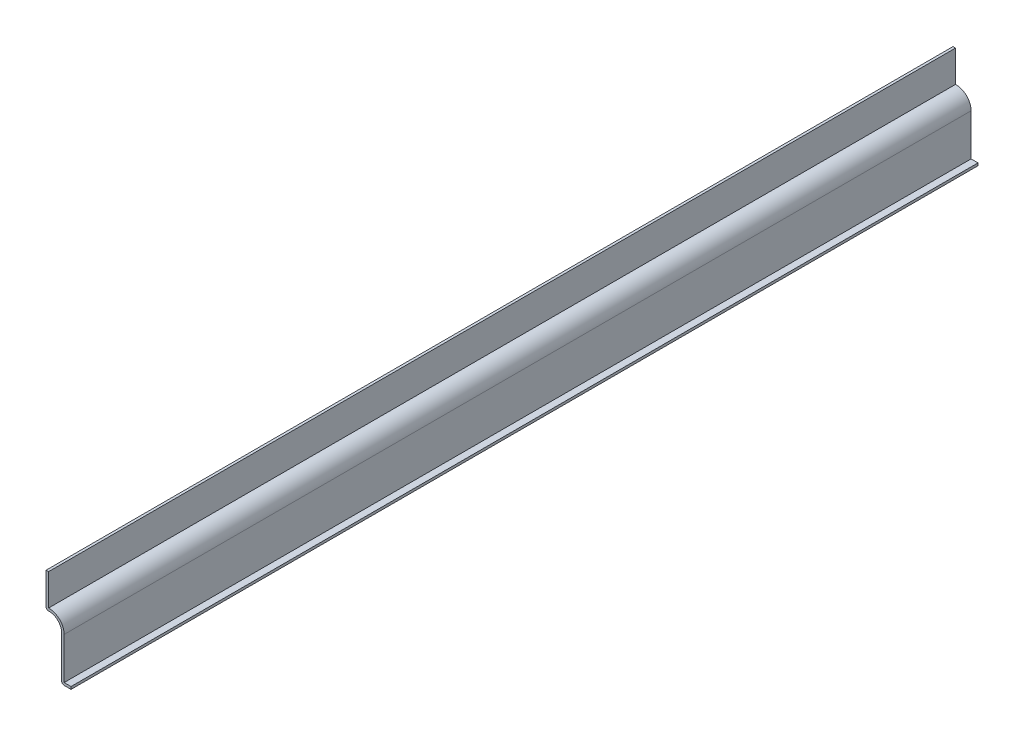
from build123d import *

# Parameters (mm, degrees)
EXTRUDE_THIN1_DEPTH = 460.375
FILLET1_R           = 1.27


with BuildPart() as part:
    # Sketch1 → Extrude-Thin1 (new body)
    with BuildSketch(Plane.XY):
        with BuildLine():
            Line((0, 0), (-4.7625, 0))
            Line((-4.7625, 0), (-4.7625, 22.426638938))
            ThreePointArc((-4.7625, 22.426638938), (-7.223935033, 27.446754723), (-12.7, 28.575))
            Line((-12.7, 28.575), (-12.7, 46.0375))
            Line((-12.7, 46.0375), (-11.43, 46.0375))
            Line((-11.43, 46.0375), (-11.43, 30.040021481))
            ThreePointArc((-11.43, 30.040021481), (-5.837793847, 27.925900252), (-3.4925, 22.426638938))
            Line((-3.4925, 22.426638938), (-3.4925, 1.27))
            Line((-3.4925, 1.27), (0, 1.27))
            Line((0, 1.27), (0, 0))
        make_face()
    extrude(amount=-EXTRUDE_THIN1_DEPTH)

    # Fillet1
    fillet1_edges = [part.edges().sort_by_distance(p)[0] for p in [
        (-4.7625, 0, -230.1875),
        (-12.7, 28.575, -230.1875),
    ]]
    fillet(fillet1_edges, radius=FILLET1_R)


solid = part.part
